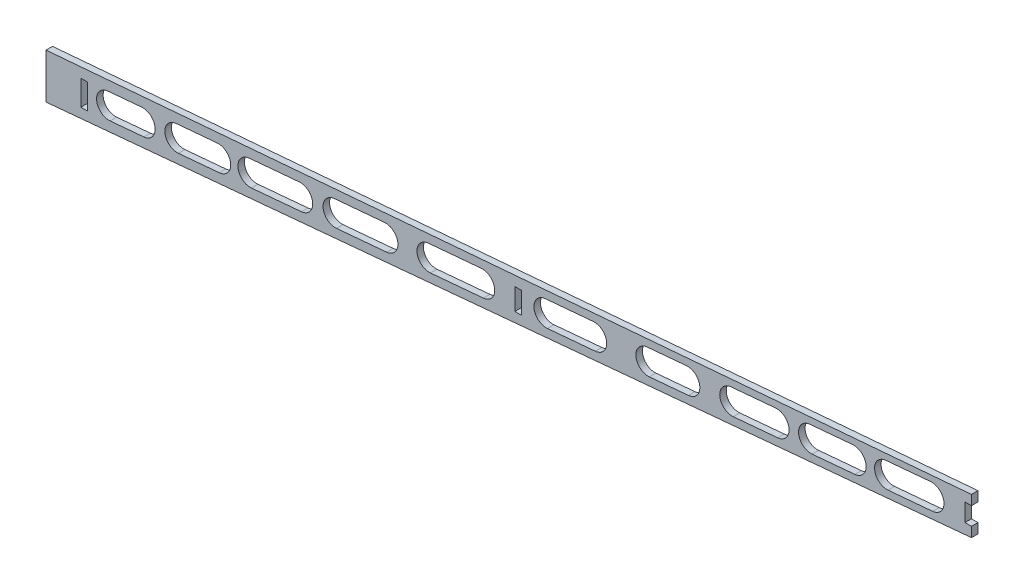
from build123d import *

# Parameters (mm, degrees)
BOSS_EXTRUDE1_DEPTH = 3
SKETCH2_W           = 3
SKETCH2_H           = 11.539364706
SKETCH2_H_2         = 9.912138823
SKETCH2_H_3         = 8.2
CUT_EXTRUDE1_DEPTH  = 10
CUT_EXTRUDE2_DEPTH  = 76.2


with BuildPart() as part:
    # Sketch1 → Boss-Extrude1 (new body)
    with BuildSketch(Plane.XY):
        Polygon((0, 0), (0, 20.67), (425, 56.476433126), (425, 39.276433126), align=None)
    extrude(amount=BOSS_EXTRUDE1_DEPTH)

    # Sketch2 → Cut-Extrude1 (cut)
    with BuildSketch(Plane.XY.offset(3)):
        with Locations((17.5, 11.748324541)):
            Rectangle(SKETCH2_W, SKETCH2_H)
        with Locations((216.8, 29.353048358)):
            Rectangle(SKETCH2_W, SKETCH2_H_2)
        with Locations((423.5, 47.876433126)):
            Rectangle(SKETCH2_W, SKETCH2_H_3)
    extrude(amount=-CUT_EXTRUDE1_DEPTH, mode=Mode.SUBTRACT)

    # Sketch4 → Cut-Extrude2 (cut)
    with BuildSketch(Plane.XY.offset(3)):
        with BuildLine():
            Line((28.430075945, 18.586671141), (43.937260326, 19.96620177))
            ThreePointArc((43.937260326, 19.96620177), (50.119919943, 14.793705267), (44.94742344, 8.611045651))
            Line((44.94742344, 8.611045651), (29.440239059, 7.231515022))
            ThreePointArc((29.440239059, 7.231515022), (23.257579443, 12.404011524), (28.430075945, 18.586671141))
        make_face()
        with BuildLine():
            Line((59.790881277, 21.376551653), (78.598406673, 23.049683067))
            ThreePointArc((78.598406673, 23.049683067), (84.78106629, 17.877186565), (79.608569787, 11.694526949))
            Line((79.608569787, 11.694526949), (60.801044391, 10.021395534))
            ThreePointArc((60.801044391, 10.021395534), (54.618384775, 15.193892037), (59.790881277, 21.376551653))
        make_face()
        with BuildLine():
            Line((229.2571326, 36.452395115), (251.2649972, 38.41023108))
            ThreePointArc((251.2649972, 38.41023108), (257.447656816, 33.237734577), (252.275160313, 27.055074961))
            Line((252.275160313, 27.055074961), (230.267295713, 25.097238996))
            ThreePointArc((230.267295713, 25.097238996), (224.084636097, 30.269735499), (229.2571326, 36.452395115))
        make_face()
        with BuildLine():
            Line((93.318457851, 24.359189743), (116.291702582, 26.40290664))
            ThreePointArc((116.291702582, 26.40290664), (122.474362199, 21.230410138), (117.301865696, 15.047750521))
            Line((117.301865696, 15.047750521), (94.328620964, 13.004033624))
            ThreePointArc((94.328620964, 13.004033624), (88.145961348, 18.176530126), (93.318457851, 24.359189743))
        make_face()
        with BuildLine():
            Line((132.414057624, 27.837163307), (155.402232027, 29.88220836))
            ThreePointArc((155.402232027, 29.88220836), (161.584891644, 24.709711857), (156.412395141, 18.527052241))
            Line((156.412395141, 18.527052241), (133.424220738, 16.482007189))
            ThreePointArc((133.424220738, 16.482007189), (127.241561121, 21.654503691), (132.414057624, 27.837163307))
        make_face()
        with BuildLine():
            Line((175.537412929, 31.673448993), (199.853242838, 33.836603264))
            ThreePointArc((199.853242838, 33.836603264), (206.035902455, 28.664106762), (200.863405952, 22.481447145))
            Line((200.863405952, 22.481447145), (176.547576043, 20.318292874))
            ThreePointArc((176.547576043, 20.318292874), (170.364916427, 25.490789377), (175.537412929, 31.673448993))
        make_face()
        with BuildLine():
            Line((276.086850874, 40.618401601), (294.056080345, 42.216957588))
            ThreePointArc((294.056080345, 42.216957588), (300.238739961, 37.044461085), (295.066243459, 30.861801469))
            Line((295.066243459, 30.861801469), (277.097013988, 29.263245482))
            ThreePointArc((277.097013988, 29.263245482), (270.914354371, 34.435741984), (276.086850874, 40.618401601))
        make_face()
        with BuildLine():
            Line((314.592454226, 44.043888646), (335.042833198, 45.863169534))
            ThreePointArc((335.042833198, 45.863169534), (341.225492815, 40.690673031), (336.052996312, 34.508013415))
            Line((336.052996312, 34.508013415), (315.60261734, 32.688732527))
            ThreePointArc((315.60261734, 32.688732527), (309.419957724, 37.86122903), (314.592454226, 44.043888646))
        make_face()
        with BuildLine():
            Line((350.794077228, 47.26441189), (370.423562276, 49.010665445))
            ThreePointArc((370.423562276, 49.010665445), (376.606221893, 43.838168943), (371.43372539, 37.655509326))
            Line((371.43372539, 37.655509326), (351.804240342, 35.909255771))
            ThreePointArc((351.804240342, 35.909255771), (345.621580725, 41.081752274), (350.794077228, 47.26441189))
        make_face()
        with BuildLine():
            Line((385.686896011, 50.36850294), (406.175047046, 52.191144058))
            ThreePointArc((406.175047046, 52.191144058), (412.357706662, 47.018647556), (407.18521016, 40.835987939))
            Line((407.18521016, 40.835987939), (386.697059125, 39.013346821))
            ThreePointArc((386.697059125, 39.013346821), (380.514399509, 44.185843323), (385.686896011, 50.36850294))
        make_face()
    extrude(amount=-CUT_EXTRUDE2_DEPTH, mode=Mode.SUBTRACT)


solid = part.part
